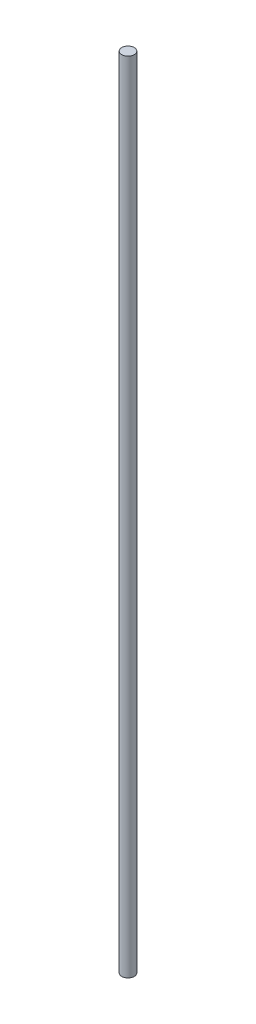
from build123d import *

# Parameters (mm, degrees)
SKETCH1_R           = 4.7625
BOSS_EXTRUDE1_DEPTH = 609.6


with BuildPart() as part:
    # Sketch1 → Boss-Extrude1 (new body)
    with BuildSketch(Plane(origin=(0, 0, 0), x_dir=(1, 0, 0), z_dir=(0, 1, 0))):
        Circle(SKETCH1_R)
    extrude(amount=BOSS_EXTRUDE1_DEPTH)


solid = part.part
